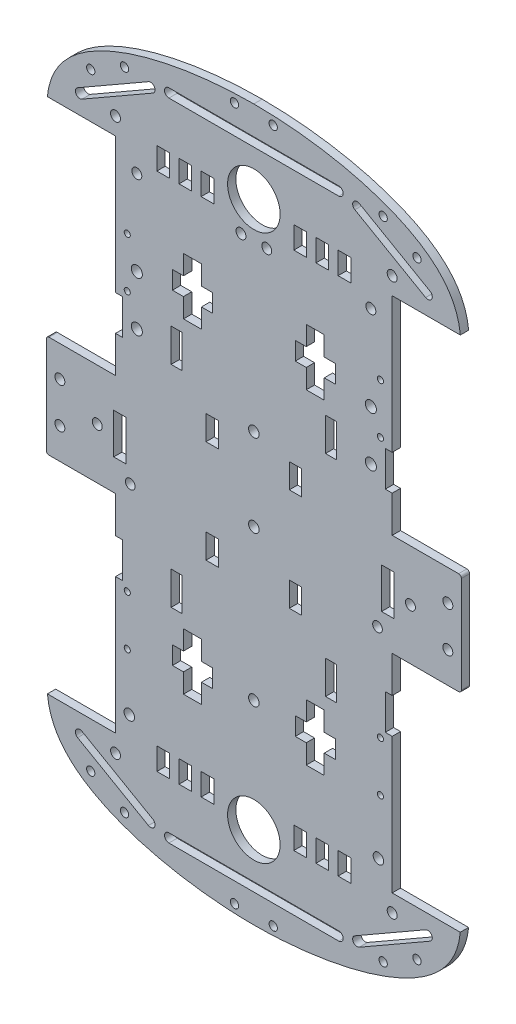
from build123d import *

# Parameters (mm, degrees)
ESBO_O1_R                = 1.5
ESBO_O1_R_2              = 1.8
ESBO_O1_R_3              = 1.9
ESBO_O1_W                = 4.6
ESBO_O1_H                = 8
ESBO_O1_R_4              = 1.75
ESBO_O1_W_2              = 4
ESBO_O1_H_2              = 12
ESBO_O1_W_3              = 4.5
ESBO_O1_H_3              = 8.864124738
ESBO_O1_R_5              = 9.5
ESBO_O1_H_4              = 14.6
ESBO_O1_R_6              = 2
RESSALTO_EXTRUS_O1_DEPTH = 3
ESBO_O2_R                = 1.1
CORTE_EXTRUS_O1_DEPTH    = 4.0000001


with BuildPart() as part:
    # Esboço1 → Ressalto-extrusão1 (new body)
    with BuildSketch(Plane.XY):
        with BuildLine():
            Line((-50, 93.462974016), (-50, 44.446894439))
            Line((-50, 44.446894439), (-47.5, 44.446894439))
            Line((-47.5, 44.446894439), (-47.5, 31.678967302))
            Line((-47.5, 31.678967302), (-50, 31.678967302))
            Line((-50, 31.678967302), (-50, 18.462974016))
            Line((-50, 18.462974016), (-74, 18.462974016))
            ThreePointArc((-74, 18.462974016), (-74.707106781, 18.170080797), (-75, 17.462974016))
            Line((-75, 17.462974016), (-75, -17.462974016))
            ThreePointArc((-75, -17.462974016), (-74.707106781, -18.170080797), (-74, -18.462974016))
            Line((-74, -18.462974016), (-50, -18.462974016))
            Line((-50, -18.462974016), (-50, -31.678967302))
            Line((-50, -31.678967302), (-47.5, -31.678967302))
            Line((-47.5, -31.678967302), (-47.5, -44.446894439))
            Line((-47.5, -44.446894439), (-50, -44.446894439))
            Line((-50, -44.446894439), (-50, -93.462974016))
            Line((-50, -93.462974016), (-74.611819038, -93.462974016))
            add(Edge.make_bspline(
                [(-74.611819038, -93.462974016), (-74.52325857, -94.421865172), (-74.263894575, -96.309278909), (-73.628118088, -99.049293996), (-72.283379025, -102.519110192), (-69.760737596, -106.54198266), (-66.394785943, -110.238931928), (-62.212791482, -113.598126854), (-57.294034108, -116.611363451), (-51.754244628, -119.273390648), (-45.728702161, -121.581494756), (-39.358370576, -123.536463608), (-32.777639293, -125.143808619), (-26.100781632, -126.417523664), (-19.41939707, -127.377439626), (-12.804718454, -128.044119277), (-7.607232748, -128.35732773), (-3.776242604, -128.474059436), (-1.253533344, -128.5), (0, -128.5)],
                knots=[0, 0, 0, 0, 0, 0, 0.066666667, 0.133333333, 0.2, 0.266666667, 0.333333333, 0.4, 0.466666667, 0.533333333, 0.6, 0.666666667, 0.733333333, 0.8, 0.866666667, 0.933333333, 1, 1, 1, 1, 1, 1], degree=5))
            add(Edge.make_bspline(
                [(74.611819038, -93.462974016), (74.52325857, -94.421865172), (74.263894575, -96.309278909), (73.628118088, -99.049293996), (72.283379025, -102.519110192), (69.760737596, -106.54198266), (66.394785943, -110.238931928), (62.212791482, -113.598126854), (57.294034108, -116.611363451), (51.754244628, -119.273390648), (45.728702161, -121.581494756), (39.358370576, -123.536463608), (32.777639293, -125.143808619), (26.100781632, -126.417523664), (19.41939707, -127.377439626), (12.804718454, -128.044119277), (7.607232748, -128.35732773), (3.776242604, -128.474059436), (1.253533344, -128.5), (0, -128.5)],
                knots=[0, 0, 0, 0, 0, 0, 0.066666667, 0.133333333, 0.2, 0.266666667, 0.333333333, 0.4, 0.466666667, 0.533333333, 0.6, 0.666666667, 0.733333333, 0.8, 0.866666667, 0.933333333, 1, 1, 1, 1, 1, 1], degree=5))
            Line((74.611819038, -93.462974016), (50, -93.462974016))
            Line((50, -93.462974016), (50, -44.446894439))
            Line((50, -44.446894439), (47.5, -44.446894439))
            Line((47.5, -44.446894439), (47.5, -31.678967302))
            Line((47.5, -31.678967302), (50, -31.678967302))
            Line((50, -31.678967302), (50, -18.462974016))
            Line((50, -18.462974016), (74, -18.462974016))
            ThreePointArc((74, -18.462974016), (74.707106781, -18.170080797), (75, -17.462974016))
            Line((75, -17.462974016), (75, 17.462974016))
            ThreePointArc((75, 17.462974016), (74.707106781, 18.170080797), (74, 18.462974016))
            Line((74, 18.462974016), (50, 18.462974016))
            Line((50, 18.462974016), (50, 31.678967302))
            Line((50, 31.678967302), (47.5, 31.678967302))
            Line((47.5, 31.678967302), (47.5, 44.446894439))
            Line((47.5, 44.446894439), (50, 44.446894439))
            Line((50, 44.446894439), (50, 93.462974016))
            Line((50, 93.462974016), (74.611819038, 93.462974016))
            add(Edge.make_bspline(
                [(0, 128.5), (1.253533344, 128.5), (3.776242604, 128.474059436), (7.607232748, 128.35732773), (12.804718454, 128.044119277), (19.41939707, 127.377439626), (26.100781632, 126.417523664), (32.777639293, 125.143808619), (39.358370576, 123.536463608), (45.728702161, 121.581494756), (51.754244628, 119.273390648), (57.294034108, 116.611363451), (62.212791482, 113.598126854), (66.394785943, 110.238931928), (69.760737596, 106.54198266), (72.283379025, 102.519110192), (73.628118088, 99.049293996), (74.263894575, 96.309278909), (74.52325857, 94.421865172), (74.611819038, 93.462974016)],
                knots=[0, 0, 0, 0, 0, 0, 0.066666667, 0.133333333, 0.2, 0.266666667, 0.333333333, 0.4, 0.466666667, 0.533333333, 0.6, 0.666666667, 0.733333333, 0.8, 0.866666667, 0.933333333, 1, 1, 1, 1, 1, 1], degree=5))
            add(Edge.make_bspline(
                [(0, 128.5), (-1.253533344, 128.5), (-3.776242604, 128.474059436), (-7.607232748, 128.35732773), (-12.804718454, 128.044119277), (-19.41939707, 127.377439626), (-26.100781632, 126.417523664), (-32.777639293, 125.143808619), (-39.358370576, 123.536463608), (-45.728702161, 121.581494756), (-51.754244628, 119.273390648), (-57.294034108, 116.611363451), (-62.212791482, 113.598126854), (-66.394785943, 110.238931928), (-69.760737596, 106.54198266), (-72.283379025, 102.519110192), (-73.628118088, 99.049293996), (-74.263894575, 96.309278909), (-74.52325857, 94.421865172), (-74.611819038, 93.462974016)],
                knots=[0, 0, 0, 0, 0, 0, 0.066666667, 0.133333333, 0.2, 0.266666667, 0.333333333, 0.4, 0.466666667, 0.533333333, 0.6, 0.666666667, 0.733333333, 0.8, 0.866666667, 0.933333333, 1, 1, 1, 1, 1, 1], degree=5))
            Line((-74.611819038, 93.462974016), (-50, 93.462974016))
        make_face()
        with Locations((-58.95619631, -109.819967605)):
            Circle(ESBO_O1_R, mode=Mode.SUBTRACT)
        with Locations((-46.74379833, -116.665209424)):
            Circle(ESBO_O1_R, mode=Mode.SUBTRACT)
        with BuildLine():
            ThreePointArc((-63.68937936, -101.721515577), (-64.2805623, -99.537367521), (-62.096414244, -98.946184581))
            Line((-62.096414244, -98.946184581), (-36.509776443, -113.632224378))
            ThreePointArc((-36.509776443, -113.632224378), (-35.918593503, -115.816372434), (-38.10274156, -116.407555374))
            Line((-38.10274156, -116.407555374), (-63.68937936, -101.721515577))
        make_face(mode=Mode.SUBTRACT)
        with Locations((-49.994380627, -99.725491141)):
            Circle(ESBO_O1_R_2, mode=Mode.SUBTRACT)
        with Locations((-45.026948509, -85.144618245)):
            Circle(ESBO_O1_R_3, mode=Mode.SUBTRACT)
        with Locations((-7, -125.317141839)):
            Circle(ESBO_O1_R, mode=Mode.SUBTRACT)
        with Locations((-32.75058154, -93.96045009)):
            Rectangle(ESBO_O1_W, ESBO_O1_H, mode=Mode.SUBTRACT)
        with Locations((-24.75058154, -93.96045009)):
            Rectangle(ESBO_O1_W, ESBO_O1_H, mode=Mode.SUBTRACT)
        with Locations((-16.75058154, -93.96045009)):
            Rectangle(ESBO_O1_W, ESBO_O1_H, mode=Mode.SUBTRACT)
        with Locations((-70.106624803, -7.3)):
            Circle(ESBO_O1_R_2, mode=Mode.SUBTRACT)
        with Locations((-44.680196114, -12.788348158)):
            Circle(ESBO_O1_R_4, mode=Mode.SUBTRACT)
        Polygon((-29.428921654, -61.983420667), (-29.428921654, -55.483420667), (-25.441649393, -55.483420667), (-25.441649393, -48.483420667), (-18.941649393, -48.483420667), (-18.941649393, -55.483420667), (-14.974715063, -55.483420667), (-14.974715063, -61.983420667), (-18.941649393, -61.983420667), (-18.941649393, -68.983420667), (-25.441649393, -68.983420667), (-25.441649393, -61.983420667), align=None, mode=Mode.SUBTRACT)
        with Locations((-27.896492833, -38.025125224)):
            Rectangle(ESBO_O1_W_2, ESBO_O1_H_2, mode=Mode.SUBTRACT)
        with Locations((-15.060393961, -18.534756411)):
            Rectangle(ESBO_O1_W_3, ESBO_O1_H_3, mode=Mode.SUBTRACT)
        with Locations((7, -125.317141839)):
            Circle(ESBO_O1_R, mode=Mode.SUBTRACT)
        with BuildLine():
            ThreePointArc((-30.698982796, -118.190228394), (-32.298982796, -116.590228394), (-30.698982796, -114.990228394))
            Line((-30.698982796, -114.990228394), (30.698982796, -114.990228394))
            ThreePointArc((30.698982796, -114.990228394), (32.298982796, -116.590228394), (30.698982796, -118.190228394))
            Line((30.698982796, -118.190228394), (-30.698982796, -118.190228394))
        make_face(mode=Mode.SUBTRACT)
        with Locations((0, -98.687197748)):
            Circle(ESBO_O1_R_5, mode=Mode.SUBTRACT)
        with Locations((16.75058154, -93.96045009)):
            Rectangle(ESBO_O1_W, ESBO_O1_H, mode=Mode.SUBTRACT)
        with Locations((24.75058154, -93.96045009)):
            Rectangle(ESBO_O1_W, ESBO_O1_H, mode=Mode.SUBTRACT)
        with Locations((32.75058154, -93.96045009)):
            Rectangle(ESBO_O1_W, ESBO_O1_H, mode=Mode.SUBTRACT)
        with Locations((46.74379833, -116.665209424)):
            Circle(ESBO_O1_R, mode=Mode.SUBTRACT)
        with BuildLine():
            Line((36.509776443, -113.632224378), (62.096414244, -98.946184581))
            ThreePointArc((62.096414244, -98.946184581), (64.2805623, -99.537367521), (63.68937936, -101.721515577))
            Line((63.68937936, -101.721515577), (38.10274156, -116.407555374))
            ThreePointArc((38.10274156, -116.407555374), (35.918593503, -115.816372434), (36.509776443, -113.632224378))
        make_face(mode=Mode.SUBTRACT)
        with Locations((49.994380627, -99.725491141)):
            Circle(ESBO_O1_R_2, mode=Mode.SUBTRACT)
        with Locations((58.95619631, -109.819967605)):
            Circle(ESBO_O1_R, mode=Mode.SUBTRACT)
        with Locations((45.026948509, -85.144618245)):
            Circle(ESBO_O1_R_3, mode=Mode.SUBTRACT)
        with Locations((0, -58.184487035)):
            Circle(ESBO_O1_R_3, mode=Mode.SUBTRACT)
        Polygon((25.441649393, -68.983420667), (18.941649393, -68.983420667), (18.941649393, -61.983420667), (14.974715063, -61.983420667), (14.974715063, -55.483420667), (18.941649393, -55.483420667), (18.941649393, -48.483420667), (25.441649393, -48.483420667), (25.441649393, -55.483420667), (29.428921654, -55.483420667), (29.428921654, -61.983420667), (25.441649393, -61.983420667), align=None, mode=Mode.SUBTRACT)
        with Locations((27.896492833, -38.025125224)):
            Rectangle(ESBO_O1_W_2, ESBO_O1_H_2, mode=Mode.SUBTRACT)
        with Locations((15.060393961, -18.534756411)):
            Rectangle(ESBO_O1_W_3, ESBO_O1_H_3, mode=Mode.SUBTRACT)
        with Locations((0, -3.869303663)):
            Circle(ESBO_O1_R_3, mode=Mode.SUBTRACT)
        with Locations((44.680196114, -12.788348158)):
            Circle(ESBO_O1_R_4, mode=Mode.SUBTRACT)
        with Locations((70.106624803, -7.3)):
            Circle(ESBO_O1_R_2, mode=Mode.SUBTRACT)
        with Locations((-70.106624803, 7.3)):
            Circle(ESBO_O1_R_2, mode=Mode.SUBTRACT)
        with Locations((-56.593422251, 0)):
            Circle(ESBO_O1_R_2, mode=Mode.SUBTRACT)
        with Locations((-48.391562432, 0)):
            Rectangle(ESBO_O1_W_3, ESBO_O1_H_4, mode=Mode.SUBTRACT)
        with Locations((-42.296893592, 36.917956561)):
            Circle(ESBO_O1_R_6, mode=Mode.SUBTRACT)
        with Locations((-42.294914368, 54.917956561)):
            Circle(ESBO_O1_R_6, mode=Mode.SUBTRACT)
        with Locations((-15.060393961, 18.534756411)):
            Rectangle(ESBO_O1_W_3, ESBO_O1_H_3, mode=Mode.SUBTRACT)
        with Locations((-27.896492833, 38.025125224)):
            Rectangle(ESBO_O1_W_2, ESBO_O1_H_2, mode=Mode.SUBTRACT)
        Polygon((-25.441649393, 68.983420667), (-18.941649393, 68.983420667), (-18.941649393, 61.983420667), (-14.974715063, 61.983420667), (-14.974715063, 55.483420667), (-18.941649393, 55.483420667), (-18.941649393, 48.483420667), (-25.441649393, 48.483420667), (-25.441649393, 55.483420667), (-29.428921654, 55.483420667), (-29.428921654, 61.983420667), (-25.441649393, 61.983420667), align=None, mode=Mode.SUBTRACT)
        with Locations((-42.291539494, 85.610657286)):
            Circle(ESBO_O1_R_2, mode=Mode.SUBTRACT)
        with Locations((-58.95619631, 109.819967605)):
            Circle(ESBO_O1_R, mode=Mode.SUBTRACT)
        with Locations((-49.994380627, 99.725491141)):
            Circle(ESBO_O1_R_2, mode=Mode.SUBTRACT)
        with BuildLine():
            Line((-36.509776443, 113.632224378), (-62.096414244, 98.946184581))
            ThreePointArc((-62.096414244, 98.946184581), (-64.2805623, 99.537367521), (-63.68937936, 101.721515577))
            Line((-63.68937936, 101.721515577), (-38.10274156, 116.407555374))
            ThreePointArc((-38.10274156, 116.407555374), (-35.918593503, 115.816372434), (-36.509776443, 113.632224378))
        make_face(mode=Mode.SUBTRACT)
        with Locations((-46.74379833, 116.665209424)):
            Circle(ESBO_O1_R, mode=Mode.SUBTRACT)
        with Locations((-32.75058154, 93.96045009)):
            Rectangle(ESBO_O1_W, ESBO_O1_H, mode=Mode.SUBTRACT)
        with Locations((-24.75058154, 93.96045009)):
            Rectangle(ESBO_O1_W, ESBO_O1_H, mode=Mode.SUBTRACT)
        with Locations((-16.75058154, 93.96045009)):
            Rectangle(ESBO_O1_W, ESBO_O1_H, mode=Mode.SUBTRACT)
        with Locations((-4.66606501, 85.606520105)):
            Circle(ESBO_O1_R_2, mode=Mode.SUBTRACT)
        with BuildLine():
            Line((-30.698982796, 118.190228394), (30.698982796, 118.190228394))
            ThreePointArc((30.698982796, 118.190228394), (32.298982796, 116.590228394), (30.698982796, 114.990228394))
            Line((30.698982796, 114.990228394), (-30.698982796, 114.990228394))
            ThreePointArc((-30.698982796, 114.990228394), (-32.298982796, 116.590228394), (-30.698982796, 118.190228394))
        make_face(mode=Mode.SUBTRACT)
        with Locations((-7, 125.317141839)):
            Circle(ESBO_O1_R, mode=Mode.SUBTRACT)
        with Locations((0, 25.949221825)):
            Circle(ESBO_O1_R_3, mode=Mode.SUBTRACT)
        with Locations((15.060393961, 18.534756411)):
            Rectangle(ESBO_O1_W_3, ESBO_O1_H_3, mode=Mode.SUBTRACT)
        with Locations((27.896492833, 38.025125224)):
            Rectangle(ESBO_O1_W_2, ESBO_O1_H_2, mode=Mode.SUBTRACT)
        Polygon((29.428921654, 61.983420667), (29.428921654, 55.483420667), (25.441649393, 55.483420667), (25.441649393, 48.483420667), (18.941649393, 48.483420667), (18.941649393, 55.483420667), (14.974715063, 55.483420667), (14.974715063, 61.983420667), (18.941649393, 61.983420667), (18.941649393, 68.983420667), (25.441649393, 68.983420667), (25.441649393, 61.983420667), align=None, mode=Mode.SUBTRACT)
        with Locations((48.391562432, 0)):
            Rectangle(ESBO_O1_W_3, ESBO_O1_H_4, mode=Mode.SUBTRACT)
        with Locations((56.593422251, 0)):
            Circle(ESBO_O1_R_2, mode=Mode.SUBTRACT)
        with Locations((70.106624803, 7.3)):
            Circle(ESBO_O1_R_2, mode=Mode.SUBTRACT)
        with Locations((42.296893592, 36.917956561)):
            Circle(ESBO_O1_R_6, mode=Mode.SUBTRACT)
        with Locations((42.294914368, 54.917956561)):
            Circle(ESBO_O1_R_6, mode=Mode.SUBTRACT)
        with Locations((4.66606501, 85.606520105)):
            Circle(ESBO_O1_R_2, mode=Mode.SUBTRACT)
        with Locations((16.75058154, 93.96045009)):
            Rectangle(ESBO_O1_W, ESBO_O1_H, mode=Mode.SUBTRACT)
        with Locations((24.75058154, 93.96045009)):
            Rectangle(ESBO_O1_W, ESBO_O1_H, mode=Mode.SUBTRACT)
        with Locations((32.75058154, 93.96045009)):
            Rectangle(ESBO_O1_W, ESBO_O1_H, mode=Mode.SUBTRACT)
        with Locations((0, 98.687197748)):
            Circle(ESBO_O1_R_5, mode=Mode.SUBTRACT)
        with Locations((7, 125.317141839)):
            Circle(ESBO_O1_R, mode=Mode.SUBTRACT)
        with Locations((42.291539494, 85.610657286)):
            Circle(ESBO_O1_R_2, mode=Mode.SUBTRACT)
        with Locations((49.994380627, 99.725491141)):
            Circle(ESBO_O1_R_2, mode=Mode.SUBTRACT)
        with BuildLine():
            ThreePointArc((36.509776443, 113.632224378), (35.918593503, 115.816372434), (38.10274156, 116.407555374))
            Line((38.10274156, 116.407555374), (63.68937936, 101.721515577))
            ThreePointArc((63.68937936, 101.721515577), (64.2805623, 99.537367521), (62.096414244, 98.946184581))
            Line((62.096414244, 98.946184581), (36.509776443, 113.632224378))
        make_face(mode=Mode.SUBTRACT)
        with Locations((46.74379833, 116.665209424)):
            Circle(ESBO_O1_R, mode=Mode.SUBTRACT)
        with Locations((58.95619631, 109.819967605)):
            Circle(ESBO_O1_R, mode=Mode.SUBTRACT)
    extrude(amount=RESSALTO_EXTRUS_O1_DEPTH)

    # Esboço2 → Corte-extrusão1 (cut, through all)
    with BuildSketch(Plane.XY.offset(3)):
        with Locations((-45.75, 47)):
            Circle(ESBO_O2_R)
        with Locations((-45.75, 65)):
            Circle(ESBO_O2_R)
        with Locations((-45.75, -65)):
            Circle(ESBO_O2_R)
        with Locations((-45.75, -47)):
            Circle(ESBO_O2_R)
        with Locations((45.75, -47)):
            Circle(ESBO_O2_R)
        with Locations((45.75, -65)):
            Circle(ESBO_O2_R)
        with Locations((45.75, 65)):
            Circle(ESBO_O2_R)
        with Locations((45.75, 47)):
            Circle(ESBO_O2_R)
    extrude(amount=-CORTE_EXTRUS_O1_DEPTH, mode=Mode.SUBTRACT)


solid = part.part
